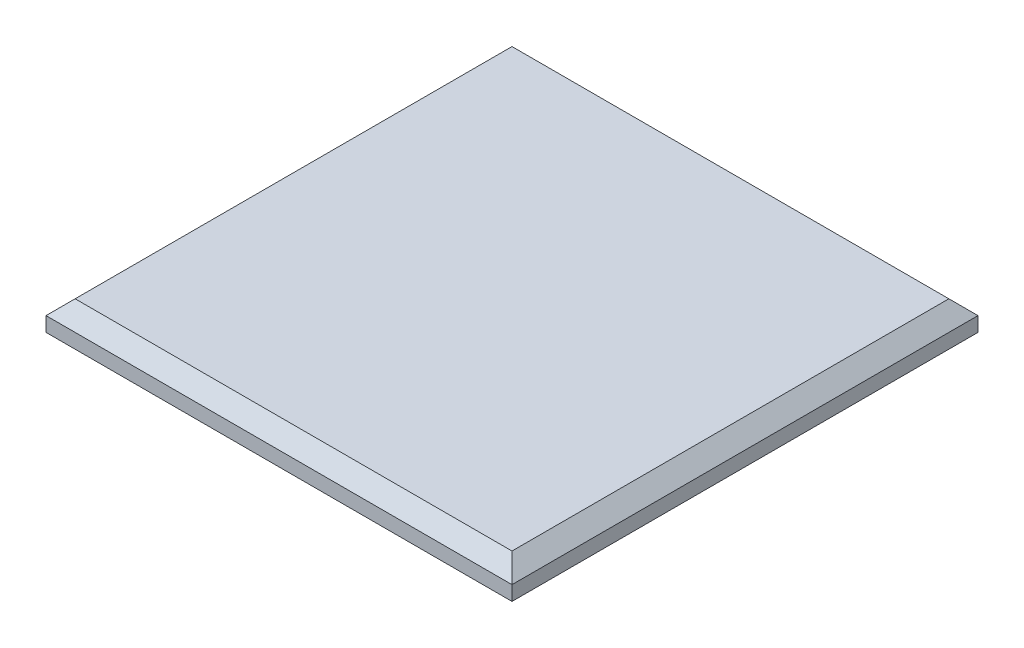
from build123d import *

# Parameters (mm, degrees)
SKETCH1_W           = 101.6
SKETCH1_H           = 101.6
BOSS_EXTRUDE1_DEPTH = 9.525
SKETCH2_W           = 101.6
SKETCH2_H           = 101.6
SKETCH2_W_2         = 94.996
SKETCH2_H_2         = 94.996
CUT_EXTRUDE1_DEPTH  = 3.175
CHAMFER1_SIZE       = 3.175


with BuildPart() as part:
    # Sketch1 → Boss-Extrude1 (new body)
    with BuildSketch(Plane(origin=(0, 0, 0), x_dir=(1, 0, 0), z_dir=(0, 1, 0))):
        Rectangle(SKETCH1_W, SKETCH1_H)
    extrude(amount=BOSS_EXTRUDE1_DEPTH)

    # Sketch2 → Cut-Extrude1 (cut)
    with BuildSketch(Plane.XZ):
        Rectangle(SKETCH2_W, SKETCH2_H)
        Rectangle(SKETCH2_W_2, SKETCH2_H_2, mode=Mode.SUBTRACT)
    extrude(amount=-CUT_EXTRUDE1_DEPTH, mode=Mode.SUBTRACT)

    # Chamfer1
    chamfer1_edges = [part.edges().sort_by_distance(p)[0] for p in [
        (-50.8, 9.525, 0),
        (0, 9.525, 50.8),
        (50.8, 9.525, 0),
        (0, 9.525, -50.8),
    ]]
    chamfer(chamfer1_edges, length=CHAMFER1_SIZE)


solid = part.part
